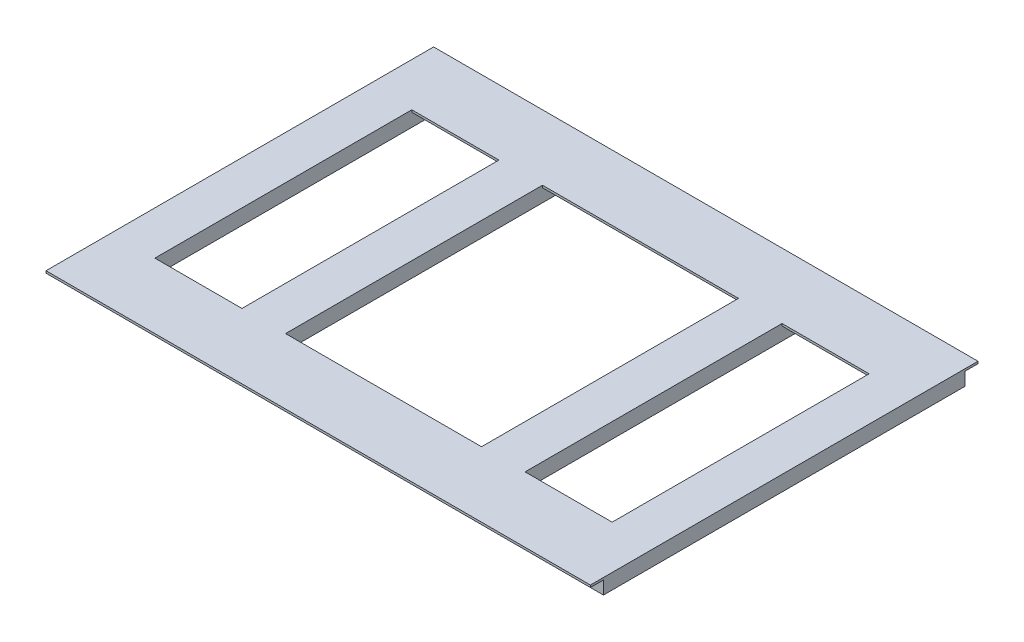
from build123d import *

# Parameters (mm, degrees)
SKETCH1_W      = 2500
SKETCH1_H      = 300
EXTRUDE1_DEPTH = 10
SKETCH2_W      = 2500
SKETCH2_H      = 20
EXTRUDE2_DEPTH = 60
SKETCH3_W      = 200
SKETCH3_H      = 590
EXTRUDE3_DEPTH = 10
SKETCH5_W      = 20
SKETCH5_H      = 810
SKETCH5_H_2    = 650
EXTRUDE7_DEPTH = 60


with BuildPart() as part:
    # Sketch1 → Extrude1 (new body)
    with BuildSketch(Plane(origin=(0, 0, 0), x_dir=(1, 0, 0), z_dir=(0, 1, 0))):
        with Locations((-1250, 150)):
            Rectangle(SKETCH1_W, SKETCH1_H)
    extrude(amount=EXTRUDE1_DEPTH)

    # Sketch2 → Extrude2 (add)
    with BuildSketch(Plane.XZ):
        with Locations((-1250, -70)):
            Rectangle(SKETCH2_W, SKETCH2_H)
        with Locations((-1250, -230)):
            Rectangle(SKETCH2_W, SKETCH2_H)
    extrude(amount=EXTRUDE2_DEPTH)

    # Sketch3 → Extrude3 (add)
    with BuildSketch(Plane.XZ):
        with Locations((-100, -595)):
            Rectangle(SKETCH3_W, SKETCH3_H)
        with Locations((-700, -595)):
            Rectangle(SKETCH3_W, SKETCH3_H)
        with Locations((-1800, -595)):
            Rectangle(SKETCH3_W, SKETCH3_H)
        with Locations((-2400, -595)):
            Rectangle(SKETCH3_W, SKETCH3_H)
    extrude(amount=-EXTRUDE3_DEPTH)

    # Sketch5 → Extrude7 (add)
    with BuildSketch(Plane.XZ):
        with Locations((-2490, -485)):
            Rectangle(SKETCH5_W, SKETCH5_H)
        with Locations((-2310, -565)):
            Rectangle(SKETCH5_W, SKETCH5_H_2)
        with Locations((-1890, -565)):
            Rectangle(SKETCH5_W, SKETCH5_H_2)
        with Locations((-1710, -565)):
            Rectangle(SKETCH5_W, SKETCH5_H_2)
        with Locations((-790, -565)):
            Rectangle(SKETCH5_W, SKETCH5_H_2)
        with Locations((-610, -565)):
            Rectangle(SKETCH5_W, SKETCH5_H_2)
        with Locations((-190, -565)):
            Rectangle(SKETCH5_W, SKETCH5_H_2)
        with Locations((-10, -485)):
            Rectangle(SKETCH5_W, SKETCH5_H)
    extrude(amount=EXTRUDE7_DEPTH)

    # Mirror2: part across face


with BuildPart() as part_1:
    add(part.part)
    add(part.part.mirror(Plane(origin=(-700, -14.090909091, -890), x_dir=(1, 0, 0), z_dir=(0, 0, -1))))


solid = part_1.part
